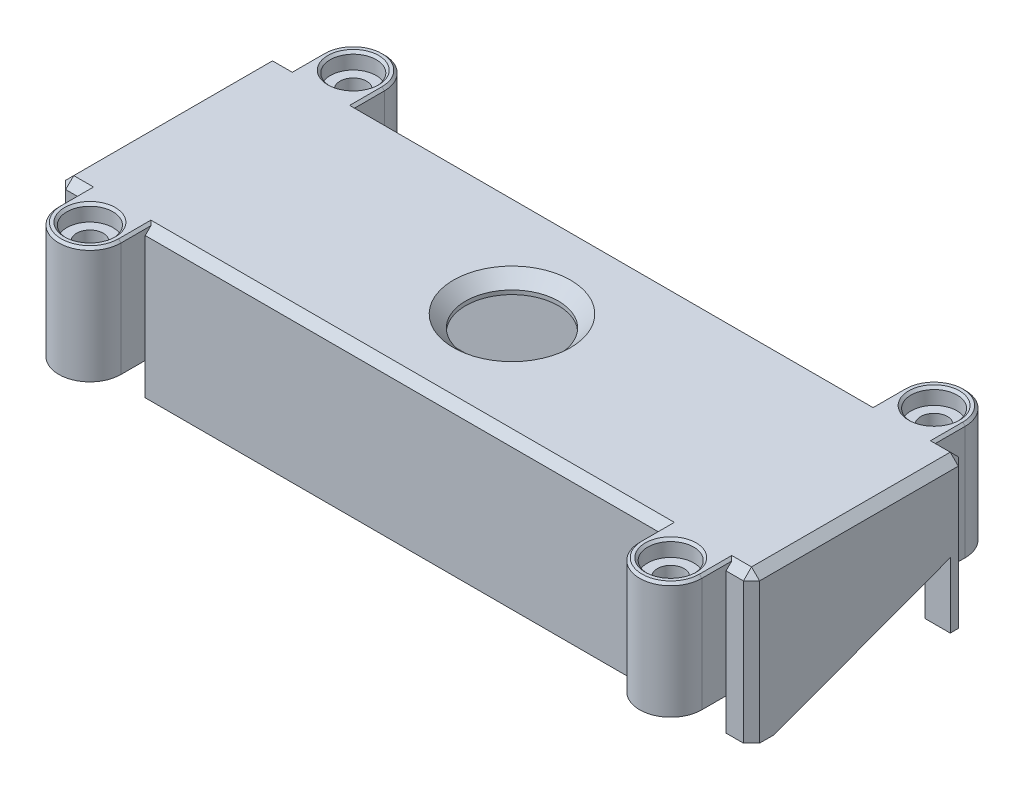
from build123d import *

# Parameters (mm, degrees)
SKETCH1_W           = 85.9
SKETCH1_H           = 26.6
BOSS_EXTRUDE1_DEPTH = 18.4
SHELL1_T            = -2
SKETCH2_R           = 5.75
CUT_EXTRUDE1_DEPTH  = 19.4
CUT_EXTRUDE2_DEPTH  = 86.9
CHAMFER1_SIZE       = 1.5
BOSS_EXTRUDE2_DEPTH = 18.4
SKETCH5_R           = 1.65
CUT_EXTRUDE3_DEPTH  = 19.4
SKETCH6_R           = 2.85
CUT_EXTRUDE4_DEPTH  = 2
CHAMFER2_SIZE       = 0.3
CHAMFER3_SIZE       = 1
SKETCH7_W           = 79.6
SKETCH7_H           = 6.85
CUT_EXTRUDE5_DEPTH  = 4
CHAMFER4_SIZE       = 0.3
SKETCH8_W           = 7.7
SKETCH8_H           = 4
CUT_EXTRUDE6_DEPTH  = 34.45


with BuildPart() as part:
    # Sketch1 → Boss-Extrude1 (new body)
    with BuildSketch(Plane(origin=(0, 0, 0), x_dir=(1, 0, 0), z_dir=(0, 1, 0))):
        with Locations((42.95, 13.3)):
            Rectangle(SKETCH1_W, SKETCH1_H)
    extrude(amount=BOSS_EXTRUDE1_DEPTH)

    # Shell1
    shell1_openings = [part.faces().sort_by_distance(p)[0] for p in [
        (42.95, 0, -13.3),
    ]]
    offset(amount=SHELL1_T, openings=shell1_openings, kind=Kind.INTERSECTION)

    # Sketch2 → Cut-Extrude1 (cut, through all)
    with BuildSketch(Plane(origin=(0, 18.4, 0), x_dir=(1, 0, 0), z_dir=(0, 1, 0))):
        with Locations((42.95, 13.3)):
            Circle(SKETCH2_R)
    extrude(amount=-CUT_EXTRUDE1_DEPTH, mode=Mode.SUBTRACT)

    # Sketch3 → Cut-Extrude2 (cut, through all)
    with BuildSketch(Plane(origin=(85.9, 0, 0), x_dir=(0, 0, -1), z_dir=(1, 0, 0))):
        Polygon((2.8125, 0), (24.6, 8.087162678), (24.6, 0), align=None)
    extrude(amount=-CUT_EXTRUDE2_DEPTH, mode=Mode.SUBTRACT)

    # Chamfer1
    chamfer1_edges = [part.edges().sort_by_distance(p)[0] for p in [
        (37.2, 18.4, -13.3),
    ]]
    chamfer(chamfer1_edges, length=CHAMFER1_SIZE)

    # Sketch4 → Boss-Extrude2 (add)
    with BuildSketch(Plane(origin=(0, 18.4, 0), x_dir=(1, 0, 0), z_dir=(0, 1, 0))):
        with BuildLine():
            Line((3.15, 29.6), (3.15, 26.6))
            Line((3.15, 26.6), (10.85, 26.6))
            Line((10.85, 26.6), (10.85, 29.6))
            ThreePointArc((10.85, 29.6), (7, 33.45), (3.15, 29.6))
        make_face()
        with BuildLine():
            Line((3.15, -3), (3.15, 0))
            Line((3.15, 0), (10.85, 0))
            Line((10.85, 0), (10.85, -3))
            ThreePointArc((10.85, -3), (7, -6.85), (3.15, -3))
        make_face()
        with BuildLine():
            Line((75.05, 0), (75.05, -3))
            ThreePointArc((75.05, -3), (78.9, -6.85), (82.75, -3))
            Line((82.75, -3), (82.75, 0))
            Line((82.75, 0), (75.05, 0))
        make_face()
        with BuildLine():
            Line((75.05, 26.6), (75.05, 29.6))
            ThreePointArc((75.05, 29.6), (78.9, 33.45), (82.75, 29.6))
            Line((82.75, 29.6), (82.75, 26.6))
            Line((82.75, 26.6), (75.05, 26.6))
        make_face()
    extrude(amount=-BOSS_EXTRUDE2_DEPTH)

    # Sketch5 → Cut-Extrude3 (cut, through all)
    with BuildSketch(Plane(origin=(0, 18.4, 0), x_dir=(1, 0, 0), z_dir=(0, 1, 0))):
        with Locations((7, 29.6)):
            Circle(SKETCH5_R)
        with Locations((7, -3)):
            Circle(SKETCH5_R)
        with Locations((78.9, -3)):
            Circle(SKETCH5_R)
        with Locations((78.9, 29.6)):
            Circle(SKETCH5_R)
    extrude(amount=-CUT_EXTRUDE3_DEPTH, mode=Mode.SUBTRACT)

    # Sketch6 → Cut-Extrude4 (cut)
    with BuildSketch(Plane(origin=(0, 18.4, 0), x_dir=(1, 0, 0), z_dir=(0, 1, 0))):
        with Locations((7, 29.6)):
            Circle(SKETCH6_R)
        with Locations((78.9, 29.6)):
            Circle(SKETCH6_R)
        with Locations((78.9, -3)):
            Circle(SKETCH6_R)
        with Locations((7, -3)):
            Circle(SKETCH6_R)
    extrude(amount=-CUT_EXTRUDE4_DEPTH, mode=Mode.SUBTRACT)

    # Chamfer2
    chamfer2_edges = [part.edges().sort_by_distance(p)[0] for p in [
        (4.15, 18.4, 3),
        (76.05, 18.4, 3),
        (76.05, 18.4, -29.6),
        (4.15, 18.4, -29.6),
    ]]
    chamfer(chamfer2_edges, length=CHAMFER2_SIZE)

    # Chamfer3
    chamfer3_edges = [part.edges().sort_by_distance(p)[0] for p in [
        (85.9, 18.4, -13.3),
        (84.325, 18.4, -26.6),
        (0, 18.4, -13.3),
        (1.575, 18.4, -26.6),
        (42.95, 18.4, 0),
        (1.575, 18.4, 0),
        (0, 9.2, -26.6),
        (85.9, 9.2, -26.6),
        (85.9, 9.2, 0),
        (0, 9.2, 0),
        (84.325, 18.4, 0),
        (42.95, 18.4, -26.6),
    ]]
    chamfer(chamfer3_edges, length=CHAMFER3_SIZE)

    # Sketch7 → Cut-Extrude5 (cut)
    with BuildSketch(Plane.XZ):
        with Locations((42.95, 3.425)):
            Rectangle(SKETCH7_W, SKETCH7_H)
        with Locations((42.95, -30.025)):
            Rectangle(SKETCH7_W, SKETCH7_H)
    extrude(amount=-CUT_EXTRUDE5_DEPTH, mode=Mode.SUBTRACT)

    # Chamfer4
    chamfer4_edges = [part.edges().sort_by_distance(p)[0] for p in [
        (7, 18.4, -33.45),
        (3.15, 18.4, -27.6),
        (10.85, 18.4, -27.6),
        (7, 18.4, 6.85),
        (10.85, 18.4, 1),
        (3.15, 18.4, 1),
        (78.9, 18.4, 6.85),
        (82.75, 18.4, 1),
        (75.05, 18.4, 1),
        (78.9, 18.4, -33.45),
        (75.05, 18.4, -27.6),
        (82.75, 18.4, -27.6),
    ]]
    chamfer(chamfer4_edges, length=CHAMFER4_SIZE)

    # Sketch8 → Cut-Extrude6 (cut, through all)
    with BuildSketch(Plane.XY):
        with Locations((7, 2)):
            Rectangle(SKETCH8_W, SKETCH8_H)
        with Locations((78.9, 2)):
            Rectangle(SKETCH8_W, SKETCH8_H)
    extrude(amount=-CUT_EXTRUDE6_DEPTH, mode=Mode.SUBTRACT)


solid = part.part
